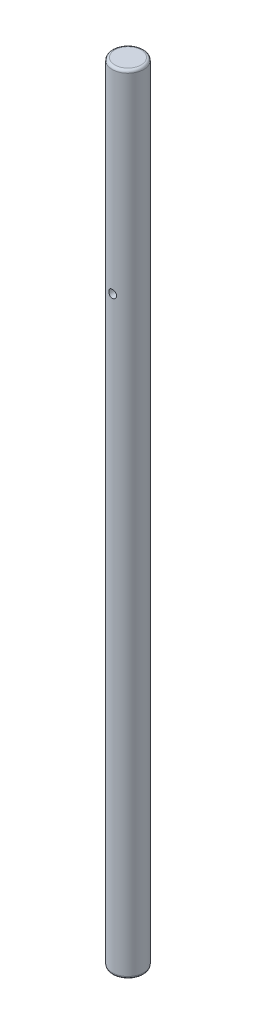
from build123d import *

# Parameters (mm, degrees)
SKETCH1_R               = 6
BOSS_EXTRUDE1_DEPTH     = 300
SKETCH2_R               = 2.5
CUT_EXTRUDE1_DEPTH      = 20
SKETCH3_R               = 1.5
CUT_EXTRUDE2_DEPTH      = 20
FILLET1_R               = 1
SKETCH4_R               = 1.5
CUT_EXTRUDE3_DEPTH      = 7.0000001
CUT_EXTRUDE3_DEPTH_BACK = 7.000000127


with BuildPart() as part:
    # Sketch1 → Boss-Extrude1 (new body)
    with BuildSketch(Plane(origin=(0, 0, 0), x_dir=(1, 0, 0), z_dir=(0, 1, 0))):
        Circle(SKETCH1_R)
    extrude(amount=BOSS_EXTRUDE1_DEPTH)

    # Sketch2 → Cut-Extrude1 (cut)
    with BuildSketch(Plane.XZ):
        Circle(SKETCH2_R)
    extrude(amount=-CUT_EXTRUDE1_DEPTH, mode=Mode.SUBTRACT)

    # Sketch3 → Cut-Extrude2 (cut)
    with BuildSketch(Plane.XY):
        with Locations((0, 5)):
            Circle(SKETCH3_R)
    extrude(amount=-CUT_EXTRUDE2_DEPTH, mode=Mode.SUBTRACT)

    # Fillet1
    fillet1_edges = [part.edges().sort_by_distance(p)[0] for p in [
        (-6, 0, 0),
        (-6, 300, 0),
    ]]
    fillet(fillet1_edges, radius=FILLET1_R)

    # Sketch4 → Cut-Extrude3 (cut, two sides)
    with BuildSketch(Plane.XY) as cut_extrude3_sk:
        with Locations((0, 225)):
            Circle(SKETCH4_R)
    extrude(amount=CUT_EXTRUDE3_DEPTH, mode=Mode.SUBTRACT)
    extrude(cut_extrude3_sk.sketch, amount=-CUT_EXTRUDE3_DEPTH_BACK, mode=Mode.SUBTRACT)


solid = part.part
